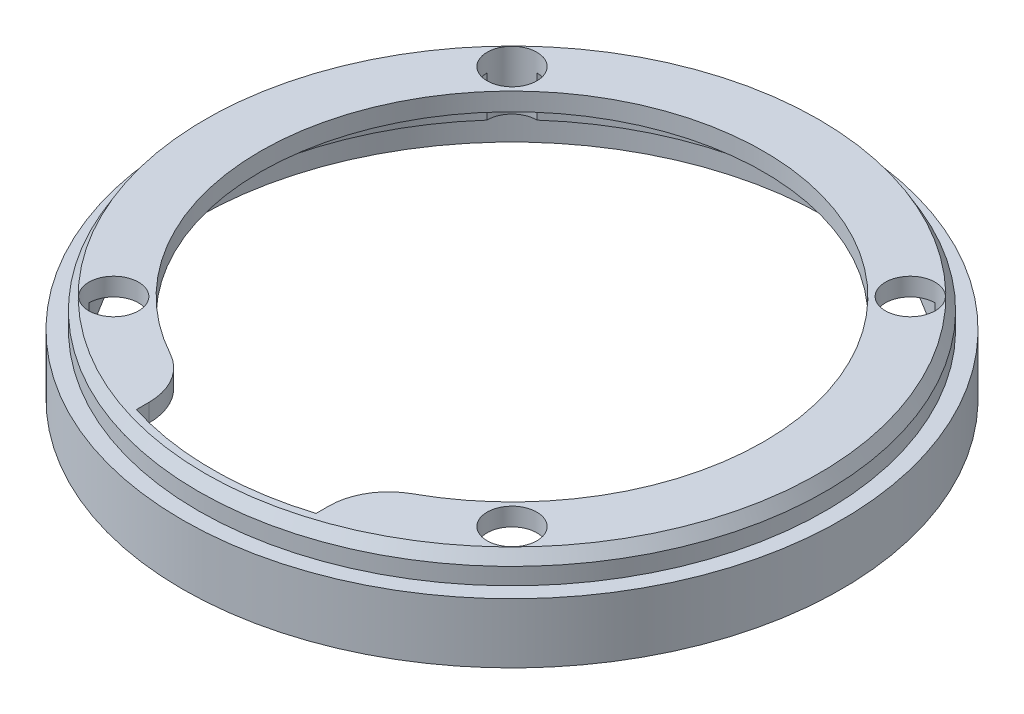
from build123d import *

# Parameters (mm, degrees)
SKETCH1_R           = 55
BOSS_EXTRUDE1_DEPTH = 14.8
SHELL1_T            = -5
SKETCH2_R           = 35
CUT_EXTRUDE1_DEPTH  = 6
SKETCH3_R           = 42
CUT_EXTRUDE2_DEPTH  = 15.8
SKETCH4_R           = 4.15
CUT_EXTRUDE3_DEPTH  = 15.8
SKETCH6_R           = 50
CUT_EXTRUDE4_DEPTH  = 2
CUT_EXTRUDE5_DEPTH  = 4
FILLET1_R           = 10
SKETCH8_OUTSIDE_W   = 143.254
SKETCH8_OUTSIDE_H   = 143.254
SKETCH8_OUTSIDE_R   = 52.35
CUT_EXTRUDE6_DEPTH  = 4.8
CHAMFER1_SIZE       = 2
CHAMFER1_SIZE2      = 1.154700538
SKETCH9_R           = 52.5
CUT_EXTRUDE7_DEPTH  = 5


with BuildPart() as part:
    # Sketch1 → Boss-Extrude1 (new body)
    with BuildSketch(Plane(origin=(0, 0, 0), x_dir=(1, 0, 0), z_dir=(0, 1, 0))):
        with Locations(Location((0, 0, 0), (0, 0, 270))):  # turned: the seam where the file's is
            Circle(SKETCH1_R)
    extrude(amount=BOSS_EXTRUDE1_DEPTH)

    # Shell1
    shell1_openings = [part.faces().sort_by_distance(p)[0] for p in [
        (0, 0, 0),
    ]]
    offset(amount=SHELL1_T, openings=shell1_openings, kind=Kind.INTERSECTION)

    # Sketch2 → Cut-Extrude1 (cut, through all)
    with BuildSketch(Plane.XZ.offset(-9.8)):
        with Locations(Location((0, 0, 0), (0, 0, 270))):  # turned: the seam where the file's is
            Circle(SKETCH2_R)
    extrude(amount=-CUT_EXTRUDE1_DEPTH, mode=Mode.SUBTRACT)

    # Sketch3 → Cut-Extrude2 (cut, through all)
    with BuildSketch(Plane(origin=(0, 14.8, 0), x_dir=(1, 0, 0), z_dir=(0, 1, 0))):
        with Locations(Location((0, 0, 0), (0, 0, 270))):  # turned: the seam where the file's is
            Circle(SKETCH3_R)
    extrude(amount=-CUT_EXTRUDE2_DEPTH, mode=Mode.SUBTRACT)

    # Sketch4 → Cut-Extrude3 (cut, through all)
    with BuildSketch(Plane(origin=(0, 14.8, 0), x_dir=(1, 0, 0), z_dir=(0, 1, 0))):
        with Locations(Location((-33.234018716, -33.234018716, 0), (0, 0, 270))):  # turned: the seam where the file's is
            Circle(SKETCH4_R)
        with Locations(Location((-33.234018716, 33.234018716, 0), (0, 0, 270))):  # turned: the seam where the file's is
            Circle(SKETCH4_R)
        with Locations(Location((33.234018716, 33.234018716, 0), (0, 0, 270))):  # turned: the seam where the file's is
            Circle(SKETCH4_R)
        with Locations(Location((33.234018716, -33.234018716, 0), (0, 0, 270))):  # turned: the seam where the file's is
            Circle(SKETCH4_R)
    extrude(amount=-CUT_EXTRUDE3_DEPTH, mode=Mode.SUBTRACT)

    # Sketch6 → Cut-Extrude4 (cut)
    with BuildSketch(Plane.XZ.offset(-9.8)):
        Circle(SKETCH6_R)
    extrude(amount=-CUT_EXTRUDE4_DEPTH, mode=Mode.SUBTRACT)

    # Sketch7 → Cut-Extrude5 (cut, through all)
    with BuildSketch(Plane.XZ.offset(-11.8)):
        with BuildLine():
            Line((15, 33.234018716), (15, 47.696960071))
            ThreePointArc((15, 47.696960071), (0, 50), (-15, 47.696960071))
            Line((-15, 47.696960071), (-15, 33.234018716))
            Line((-15, 33.234018716), (15, 33.234018716))
        make_face()
    extrude(amount=-CUT_EXTRUDE5_DEPTH, mode=Mode.SUBTRACT)

    # Fillet1
    fillet1_edges = [part.edges().sort_by_distance(p)[0] for p in [
        (-15, 13.3, 39.230090492),
        (15, 13.3, 39.230090492),
    ]]
    fillet(fillet1_edges, radius=FILLET1_R)

    # Sketch8 outside → Cut-Extrude6 (cut)
    with BuildSketch(Plane(origin=(0, 14.8, 0), x_dir=(1, 0, 0), z_dir=(0, 1, 0))):
        Rectangle(SKETCH8_OUTSIDE_W, SKETCH8_OUTSIDE_H)
        with Locations(Location((0, 0, 0), (0, 0, 270))):  # turned: the seam where the file's is
            Circle(SKETCH8_OUTSIDE_R, mode=Mode.SUBTRACT)
    extrude(amount=-CUT_EXTRUDE6_DEPTH, mode=Mode.SUBTRACT)

    # Chamfer1
    chamfer1_edges = [part.edges().sort_by_distance(p)[0] for p in [
        (0, 14.8, -52.35),
    ]]
    chamfer1_side = [part.faces().sort_by_distance(p)[0] for p in [
        (0, 12.4, -52.35),
    ]]
    chamfer(chamfer1_edges, length=CHAMFER1_SIZE, length2=CHAMFER1_SIZE2, reference=chamfer1_side[0])

    # Sketch9 → Cut-Extrude7 (cut)
    with BuildSketch(Plane.XZ):
        with Locations(Location((0, 0, 0), (0, 0, 270))):  # turned: the seam where the file's is
            Circle(SKETCH9_R)
    extrude(amount=-CUT_EXTRUDE7_DEPTH, mode=Mode.SUBTRACT)


solid = part.part
